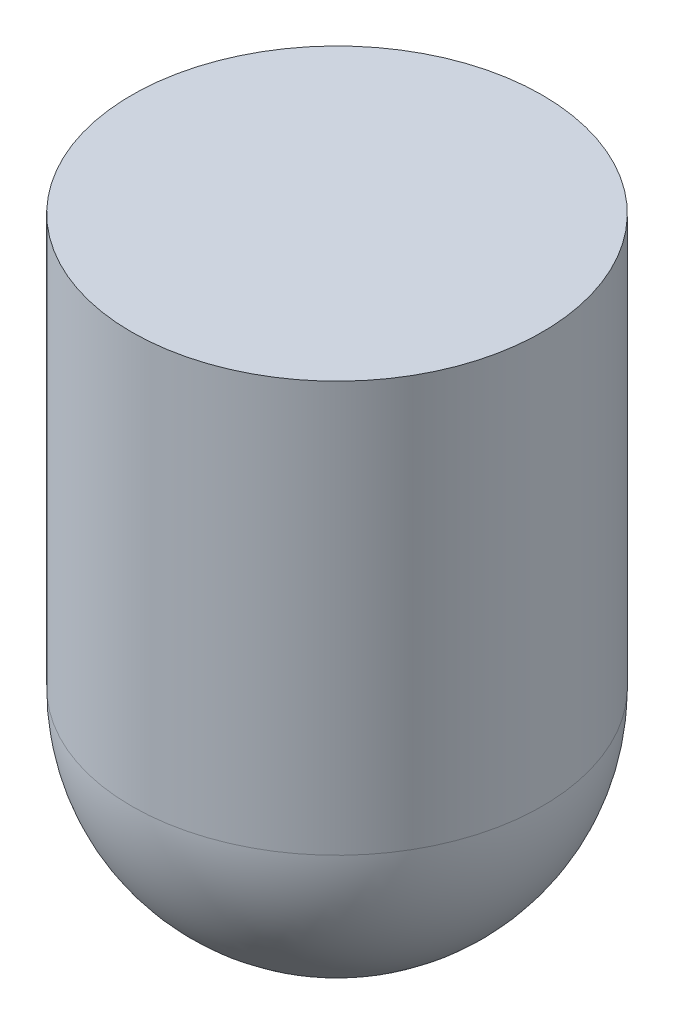
from build123d import *

# Parameters (mm, degrees)
SKETCH1_R           = 50
BOSS_EXTRUDE1_DEPTH = 100


with BuildPart() as part:
    # Sketch1 → Boss-Extrude1 (new body)
    with BuildSketch(Plane(origin=(0, 0, 0), x_dir=(1, 0, 0), z_dir=(0, 1, 0))):
        Circle(SKETCH1_R)
    extrude(amount=BOSS_EXTRUDE1_DEPTH)

    # Sketch2 → Revolve1 (revolve)
    with BuildSketch(Plane(origin=(0, 0, 0), x_dir=(0, 0, -1), z_dir=(1, 0, 0))):
        with BuildLine():
            Line((-50, 0), (0, 0))
            Line((0, 0), (0, -50))
            ThreePointArc((0, -50), (-35.355339059, -35.355339059), (-50, 0))
        make_face()
    revolve(axis=Axis((0, 0, 0), (0, -1, 0)))


solid = part.part
